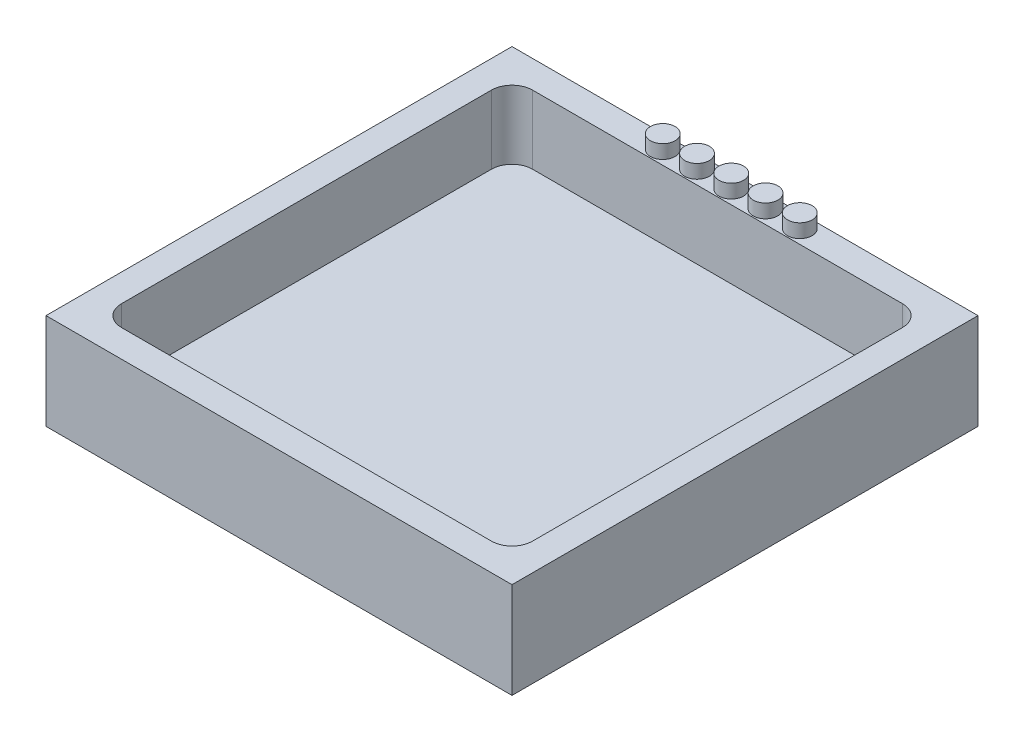
from build123d import *

# Parameters (mm, degrees)
SKETCH1_W           = 30
SKETCH1_H           = 30
BOSS_EXTRUDE2_DEPTH = 2
SKETCH1_6_W         = 34
SKETCH1_6_H         = 34
SKETCH1_6_W_2       = 30
SKETCH1_6_H_2       = 30
BOSS_EXTRUDE3_DEPTH = 7
FILLET1_R           = 1.5
SKETCH2_R           = 0.9
BOSS_EXTRUDE4_DEPTH = 1


with BuildPart() as part:
    # Sketch1 → Boss-Extrude2 (new body)
    with BuildSketch(Plane(origin=(0, 0, 0), x_dir=(1, 0, 0), z_dir=(0, 1, 0))):
        Rectangle(SKETCH1_W, SKETCH1_H)
    extrude(amount=BOSS_EXTRUDE2_DEPTH)

    # Sketch1_6 → Boss-Extrude3 (add)
    with BuildSketch(Plane(origin=(0, 0, 0), x_dir=(1, 0, 0), z_dir=(0, 1, 0))):
        Rectangle(SKETCH1_6_W, SKETCH1_6_H)
        Rectangle(SKETCH1_6_W_2, SKETCH1_6_H_2, mode=Mode.SUBTRACT)
    extrude(amount=BOSS_EXTRUDE3_DEPTH)

    # Fillet1
    fillet1_edges = [part.edges().sort_by_distance(p)[0] for p in [
        (15, 4.5, -15),
        (-15, 4.5, -15),
        (-15, 4.5, 15),
        (15, 4.5, 15),
    ]]
    fillet(fillet1_edges, radius=FILLET1_R)

    # Sketch2 → Boss-Extrude4 (add)
    with BuildSketch(Plane(origin=(0, 7, 0), x_dir=(1, 0, 0), z_dir=(0, 1, 0))):
        with Locations((0, 16)):
            Circle(SKETCH2_R)
        with Locations((-2.5, 16)):
            Circle(SKETCH2_R)
        with Locations((-5, 16)):
            Circle(SKETCH2_R)
        with Locations((2.5, 16)):
            Circle(SKETCH2_R)
        with Locations((5, 16)):
            Circle(SKETCH2_R)
    extrude(amount=BOSS_EXTRUDE4_DEPTH)


solid = part.part
